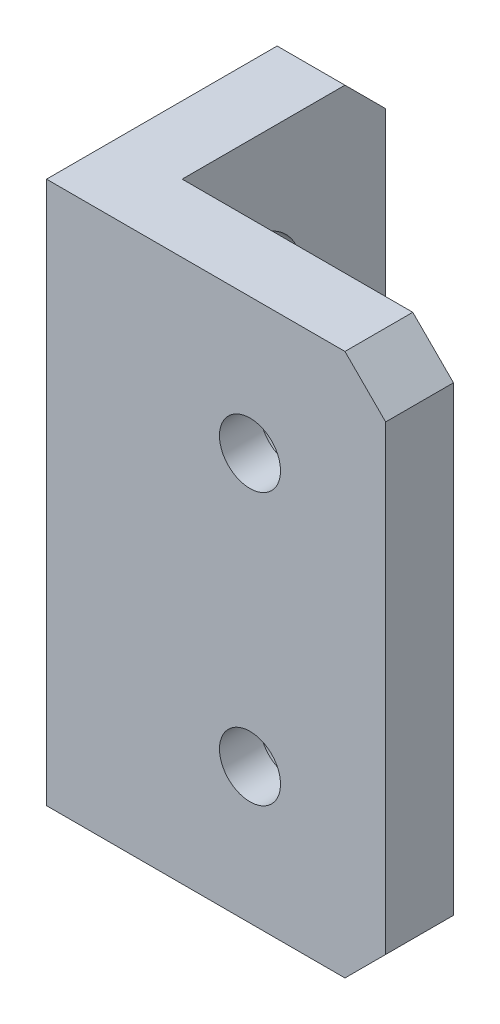
from build123d import *

# Parameters (mm, degrees)
BOSS_EXTRUDE1_DEPTH = 40
CUT_EXTRUDE1_REACH  = 27
SKETCH2_R           = 2.25
CUT_EXTRUDE2_REACH  = 7
SKETCH3_R           = 2.25
SKETCH4_R           = 3.75
CUT_EXTRUDE3_DEPTH  = 2
SKETCH5_R           = 3.75
CUT_EXTRUDE4_DEPTH  = 2
CHAMFER1_SIZE       = 3


with BuildPart() as part:
    # Sketch1 → Boss-Extrude1 (new body)
    with BuildSketch(Plane(origin=(0, 0, 0), x_dir=(1, 0, 0), z_dir=(0, 1, 0))):
        Polygon((0, 0), (25, 0), (25, 5), (5, 5), (5, 20), (0, 20), align=None)
    extrude(amount=BOSS_EXTRUDE1_DEPTH)

    # Sketch2 → Cut-Extrude1 (cut, up to next)
    with BuildSketch(Plane.ZY, mode=Mode.PRIVATE) as cut_extrude1_sk1:
        with Locations((-10, 10)):
            Circle(SKETCH2_R)
    cut_extrude1_tool1 = extrude(cut_extrude1_sk1.sketch, amount=-CUT_EXTRUDE1_REACH, mode=Mode.PRIVATE) & part.part
    add(cut_extrude1_tool1.solids().sort_by_distance((0, 10, -10))[0], mode=Mode.SUBTRACT)
    # Sketch2 → Cut-Extrude1 (cut, up to next)
    with BuildSketch(Plane.ZY, mode=Mode.PRIVATE) as cut_extrude1_sk2:
        with Locations((-10, 30)):
            Circle(SKETCH2_R)
    cut_extrude1_tool2 = extrude(cut_extrude1_sk2.sketch, amount=-CUT_EXTRUDE1_REACH, mode=Mode.PRIVATE) & part.part
    add(cut_extrude1_tool2.solids().sort_by_distance((0, 30, -10))[0], mode=Mode.SUBTRACT)

    # Sketch3 → Cut-Extrude2 (cut, up to next)
    with BuildSketch(Plane(origin=(0, 0, -5), x_dir=(-1, 0, 0), z_dir=(0, 0, -1)), mode=Mode.PRIVATE) as cut_extrude2_sk1:
        with Locations((-15, 10)):
            Circle(SKETCH3_R)
    cut_extrude2_tool1 = extrude(cut_extrude2_sk1.sketch, amount=-CUT_EXTRUDE2_REACH, mode=Mode.PRIVATE) & part.part
    add(cut_extrude2_tool1.solids().sort_by_distance((15, 10, -5))[0], mode=Mode.SUBTRACT)
    # Sketch3 → Cut-Extrude2 (cut, up to next)
    with BuildSketch(Plane(origin=(0, 0, -5), x_dir=(-1, 0, 0), z_dir=(0, 0, -1)), mode=Mode.PRIVATE) as cut_extrude2_sk2:
        with Locations((-15, 30)):
            Circle(SKETCH3_R)
    cut_extrude2_tool2 = extrude(cut_extrude2_sk2.sketch, amount=-CUT_EXTRUDE2_REACH, mode=Mode.PRIVATE) & part.part
    add(cut_extrude2_tool2.solids().sort_by_distance((15, 30, -5))[0], mode=Mode.SUBTRACT)

    # Sketch4 → Cut-Extrude3 (cut)
    with BuildSketch(Plane(origin=(0, 0, -5), x_dir=(-1, 0, 0), z_dir=(0, 0, -1))):
        with Locations((-15, 10)):
            Circle(SKETCH4_R)
        with Locations((-15, 30)):
            Circle(SKETCH4_R)
    extrude(amount=-CUT_EXTRUDE3_DEPTH, mode=Mode.SUBTRACT)

    # Sketch5 → Cut-Extrude4 (cut)
    with BuildSketch(Plane(origin=(5, 0, 0), x_dir=(0, 0, -1), z_dir=(1, 0, 0))):
        with Locations((10, 30)):
            Circle(SKETCH5_R)
        with Locations((10, 10)):
            Circle(SKETCH5_R)
    extrude(amount=-CUT_EXTRUDE4_DEPTH, mode=Mode.SUBTRACT)

    # Chamfer1
    chamfer1_edges = [part.edges().sort_by_distance(p)[0] for p in [
        (25, 40, -2.5),
        (2.5, 40, -20),
        (2.5, 0, -20),
        (25, 0, -2.5),
    ]]
    chamfer(chamfer1_edges, length=CHAMFER1_SIZE)


solid = part.part
